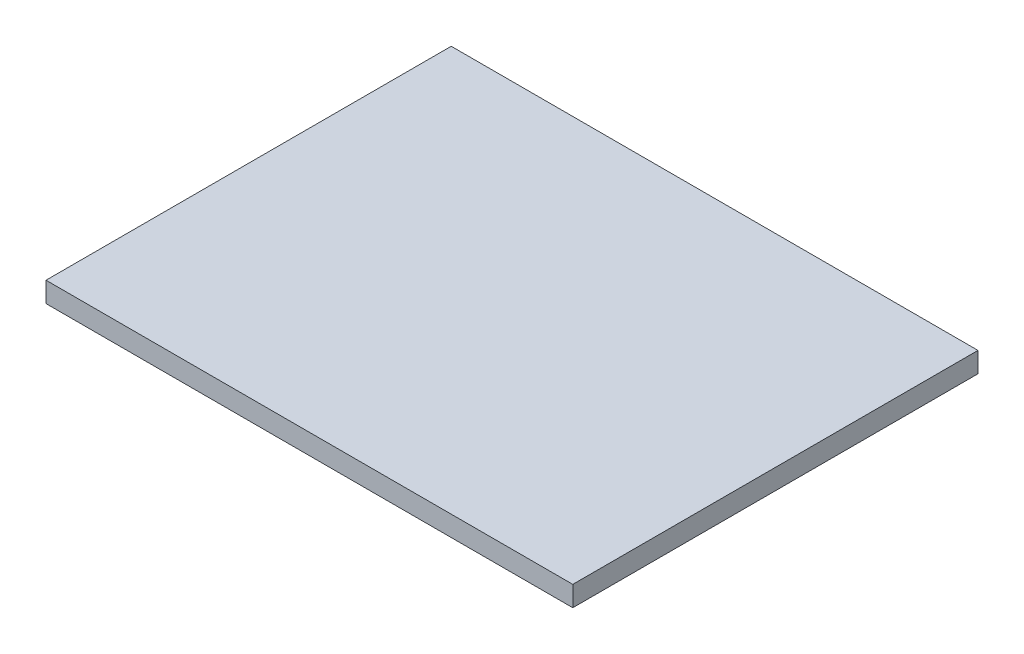
from build123d import *

# Parameters (mm, degrees)
SKETCH1_W           = 120
SKETCH1_H           = 90
BOSS_EXTRUDE1_DEPTH = 5
SKETCH2_W           = 130
SKETCH2_H           = 100
BOSS_EXTRUDE2_DEPTH = 5


with BuildPart() as part:
    # Sketch1 → Boss-Extrude1 (new body)
    with BuildSketch(Plane(origin=(0, 0, 0), x_dir=(1, 0, 0), z_dir=(0, 1, 0))):
        Rectangle(SKETCH1_W, SKETCH1_H)
    extrude(amount=BOSS_EXTRUDE1_DEPTH)

    # Sketch2 → Boss-Extrude2 (add)
    with BuildSketch(Plane(origin=(0, 5, 0), x_dir=(1, 0, 0), z_dir=(0, 1, 0))):
        Rectangle(SKETCH2_W, SKETCH2_H)
    extrude(amount=BOSS_EXTRUDE2_DEPTH)


solid = part.part
